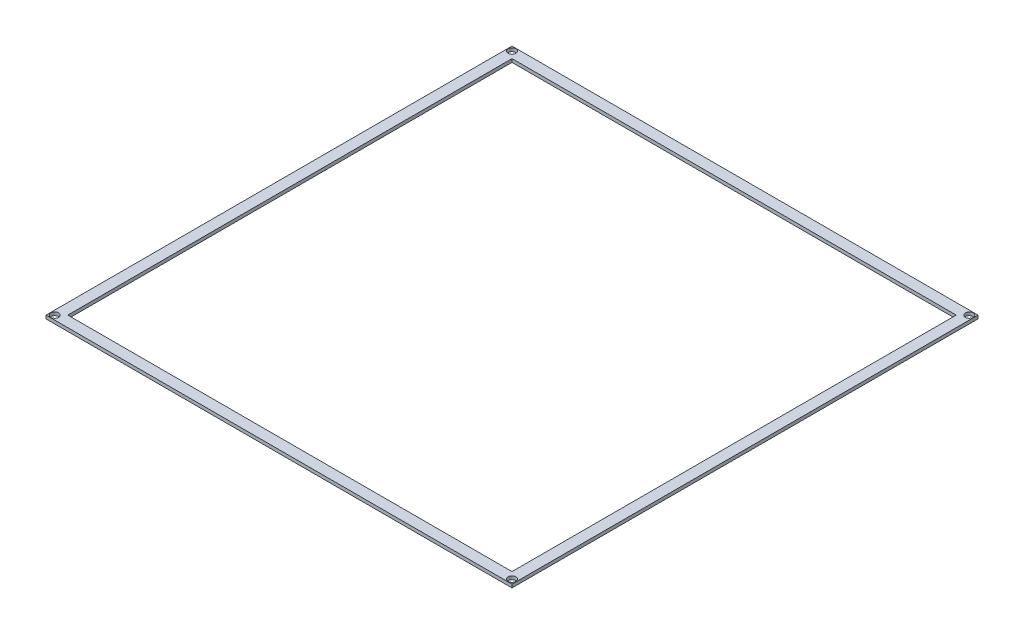
from build123d import *

# Parameters (mm, degrees)
SKETCH1_W            = 214
SKETCH1_H            = 214
BOSS_EXTRUDE1_DEPTH  = 1.51892
SKETCH2_W            = 204
SKETCH2_H            = 204
CUT_EXTRUDE1_DEPTH   = 1.51892
M3_CLEARANCE_HOLE1_D = 3.6


with BuildPart() as part:
    # Sketch1 → Boss-Extrude1 (new body)
    with BuildSketch(Plane(origin=(0, 0, 0), x_dir=(1, 0, 0), z_dir=(0, 1, 0))):
        Rectangle(SKETCH1_W, SKETCH1_H)
    extrude(amount=BOSS_EXTRUDE1_DEPTH)

    # Sketch2 → Cut-Extrude1 (cut)
    with BuildSketch(Plane(origin=(0, 1.51892, 0), x_dir=(1, 0, 0), z_dir=(0, 1, 0))):
        Rectangle(SKETCH2_W, SKETCH2_H)
    extrude(amount=-CUT_EXTRUDE1_DEPTH, mode=Mode.SUBTRACT)

    # M3 Clearance Hole1 (through all)
    with Locations(Plane(origin=(0, 1.51892, 0), x_dir=(1, 0, 0), z_dir=(0, 1, 0))):
        with Locations((-105, 105), (105, 105), (105, -105), (-105, -105)):
            Hole(M3_CLEARANCE_HOLE1_D / 2)


solid = part.part
